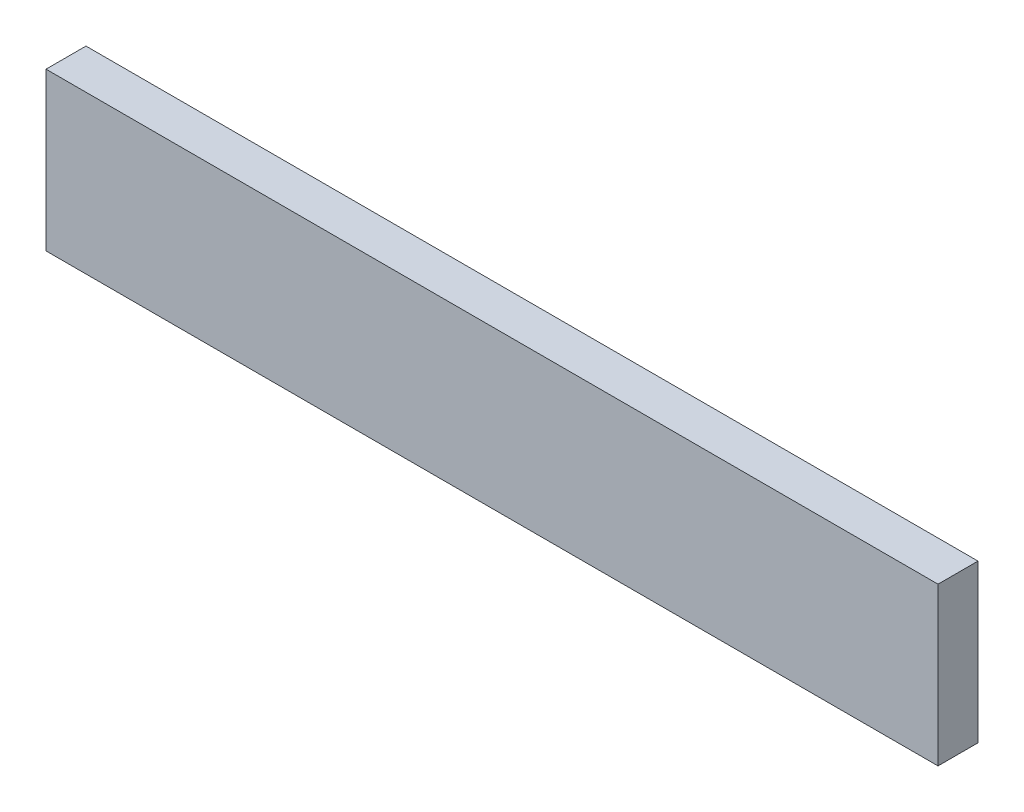
from build123d import *

# Parameters (mm, degrees)
SKETCH1_W           = 68
SKETCH1_H           = 12
BOSS_EXTRUDE1_DEPTH = 3.048


with BuildPart() as part:
    # Sketch1 → Boss-Extrude1 (new body)
    with BuildSketch(Plane.XY):
        Rectangle(SKETCH1_W, SKETCH1_H)
    extrude(amount=BOSS_EXTRUDE1_DEPTH)


solid = part.part
